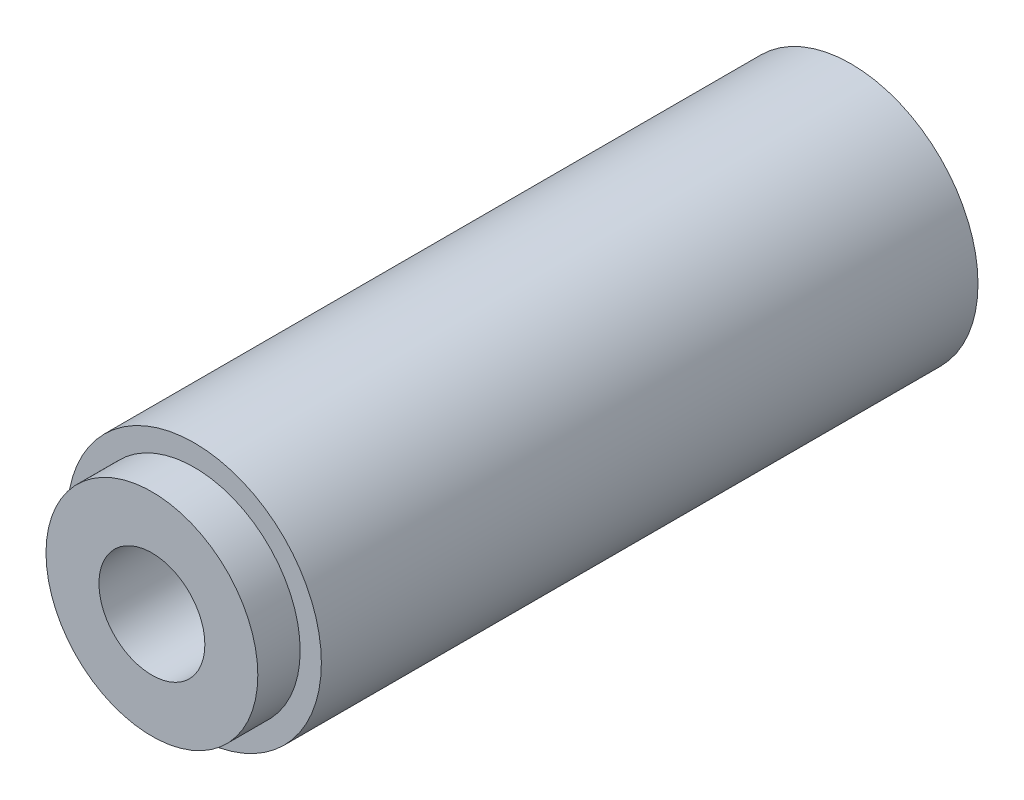
from build123d import *

# Parameters (mm, degrees)
SKETCH1_R           = 6
BOSS_EXTRUDE1_DEPTH = 31
SKETCH2_R           = 5
BOSS_EXTRUDE2_DEPTH = 2
SKETCH3_R           = 2.5
CUT_EXTRUDE1_DEPTH  = 5


with BuildPart() as part:
    # Sketch1 → Boss-Extrude1 (new body)
    with BuildSketch(Plane.XY):
        Circle(SKETCH1_R)
    extrude(amount=BOSS_EXTRUDE1_DEPTH)

    # Sketch2 → Boss-Extrude2 (add)
    with BuildSketch(Plane.XY.offset(31)):
        Circle(SKETCH2_R)
    extrude(amount=BOSS_EXTRUDE2_DEPTH)

    # Sketch3 → Cut-Extrude1 (cut)
    with BuildSketch(Plane.XY.offset(33)):
        Circle(SKETCH3_R)
    extrude(amount=-CUT_EXTRUDE1_DEPTH, mode=Mode.SUBTRACT)


solid = part.part
